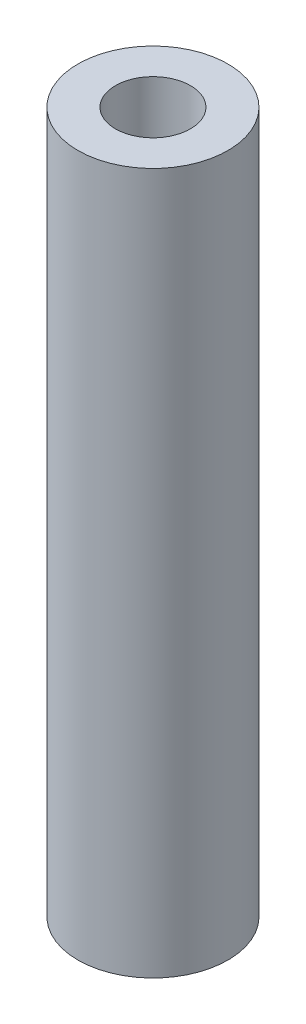
from build123d import *

# Parameters (mm, degrees)
SKETCH1_R           = 6.35
SKETCH1_R_2         = 3.175
BOSS_EXTRUDE1_DEPTH = 59.36234


with BuildPart() as part:
    # Sketch1 → Boss-Extrude1 (new body)
    with BuildSketch(Plane(origin=(0, 0, 0), x_dir=(1, 0, 0), z_dir=(0, 1, 0))):
        Circle(SKETCH1_R)
        Circle(SKETCH1_R_2, mode=Mode.SUBTRACT)
    extrude(amount=BOSS_EXTRUDE1_DEPTH)


solid = part.part
